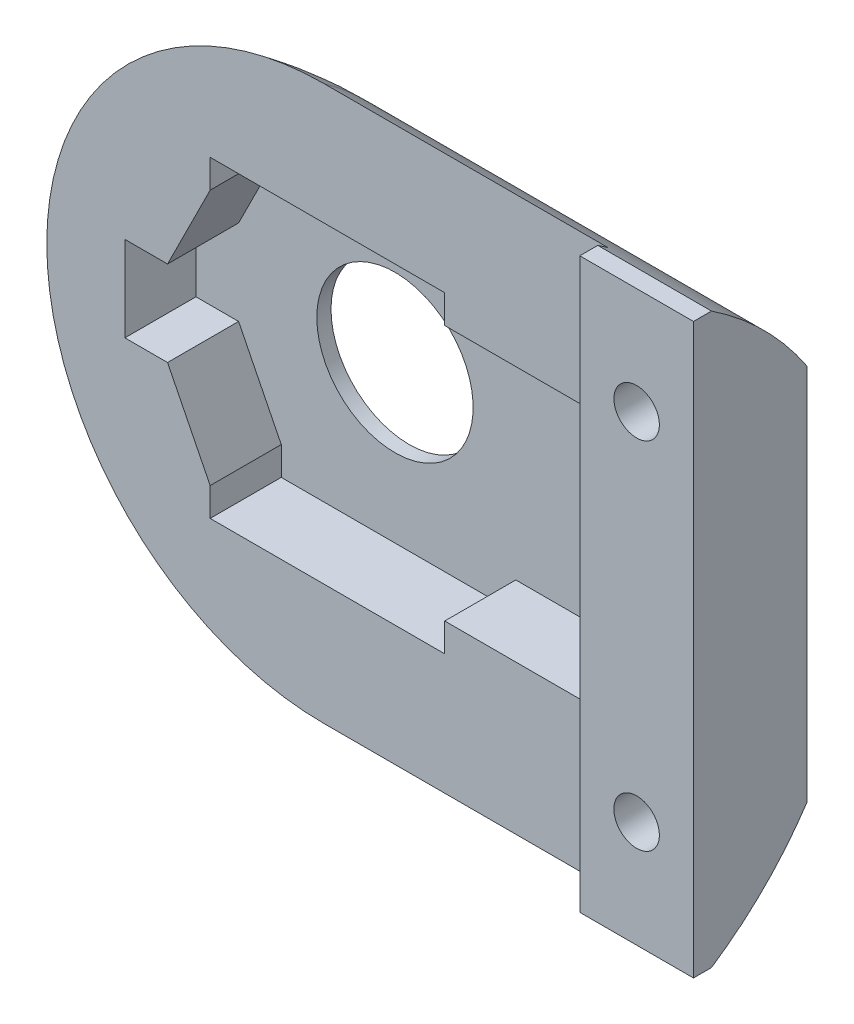
from build123d import *

# Parameters (mm, degrees)
SKETCH1_R           = 10
BOSS_EXTRUDE1_DEPTH = 4
BODY_START          = 5
SKETCH2_R           = 10
BODY_HOLE_DEPTH     = 2
SKETCH5_R           = 0.8
SCREW_HOLES_DEPTH   = 5
SKETCH6_R           = 1.25
SCREW_HEADS_DEPTH   = 2
POT_START           = 0.5
POT_INSERT_DEPTH    = 2.5
SKETCH4_R           = 2.75
POT_HOLE_DEPTH      = 5
CUT_REVOLVE6_ANGLE  = 180
CUT_EXTRUDE1_DEPTH  = 14.999999999


with BuildPart() as part:
    # Sketch1 → Boss-Extrude1 (new body)
    with BuildSketch(Plane.XY):
        Circle(SKETCH1_R)
        with BuildLine():
            Line((13.999999999, 10), (-1e-09, 10))
            ThreePointArc((-1e-09, 10), (7.071067811, 7.071067812), (9.999999999, 0))
            ThreePointArc((9.999999999, 0), (7.071067811, -7.071067812), (-1e-09, -10))
            Line((-1e-09, -10), (13.999999999, -10))
            Line((13.999999999, -10), (13.999999999, 10))
        make_face()
    extrude(amount=BOSS_EXTRUDE1_DEPTH)

    # Sketch2 → Body Hole (cut)
    with BuildSketch(Plane.XY.offset(BODY_START)):
        Circle(SKETCH2_R)
        with BuildLine():
            Line((9.999999999, 10), (-1e-09, 10))
            ThreePointArc((-1e-09, 10), (7.071067811, 7.071067812), (9.999999999, 0))
            Line((9.999999999, 0), (9.999999999, 10))
        make_face()
        with BuildLine():
            Line((9.999999999, -10), (9.999999999, 0))
            ThreePointArc((9.999999999, 0), (7.071067811, -7.071067812), (-1e-09, -10))
            Line((-1e-09, -10), (9.999999999, -10))
        make_face()
    extrude(amount=-BODY_HOLE_DEPTH, mode=Mode.SUBTRACT)

    # Sketch5 → Screw Holes (cut, through all)
    with BuildSketch(Plane.XY):
        with Locations((11.999999999, 6.25)):
            Circle(SKETCH5_R)
        with Locations((11.999999999, -6.25)):
            Circle(SKETCH5_R)
    extrude(amount=SCREW_HOLES_DEPTH, mode=Mode.SUBTRACT)

    # Sketch6 → Screw Heads (cut)
    with BuildSketch(Plane.XY):
        with Locations((11.999999999, -6.25)):
            Circle(SKETCH6_R)
    extrude(amount=SCREW_HEADS_DEPTH, mode=Mode.SUBTRACT)

    # Sketch3 → Pot Insert (cut)
    with BuildSketch(Plane(origin=(28.28760271, 0, 0), x_dir=(1, 0, 0), z_dir=(0, 0, 1)).offset(POT_START)):
        Polygon((-35.287602709, 0), (-35.287602709, -1.5), (-33.787602709, -1.5), (-32.287602709, -4.5), (-32.287602709, -5.5), (-28.287602709, -5.5), (-24.037602709, -5.5), (-24.037602709, -4.5), (-18.787602709, -4.5), (-18.787602709, 0), (-18.787602709, 4.5), (-24.037602709, 4.5), (-24.037602709, 5.5), (-28.287602709, 5.5), (-32.287602709, 5.5), (-32.287602709, 4.5), (-33.787602709, 1.5), (-35.287602709, 1.5), align=None)
    extrude(amount=POT_INSERT_DEPTH, mode=Mode.SUBTRACT)

    # Sketch4 → Pot Hole (cut, through all)
    with BuildSketch(Plane.XY):
        Circle(SKETCH4_R)
    extrude(amount=POT_HOLE_DEPTH, mode=Mode.SUBTRACT)

    # Sketch11 → Cut-Revolve6 (revolve, cut)
    with BuildSketch(Plane(origin=(0, 0, 0), x_dir=(0, 0, -1), z_dir=(1, 0, 0))):
        with BuildLine():
            Line((1.680646386, 2.75), (2, 2.75))
            Line((2, 2.75), (2, 12))
            Line((2, 12), (-10, 12))
            ThreePointArc((-10, 12), (-2.550167787, 9.407443861), (1.680646386, 2.75))
        make_face()
    revolve(axis=Axis((0, 0, 0), (0, 0, 1)), revolution_arc=CUT_REVOLVE6_ANGLE, mode=Mode.SUBTRACT)

    # Sketch13 → Cut-Extrude1 (cut, through all)
    with BuildSketch(Plane(origin=(0, 0, 0), x_dir=(0, 0, -1), z_dir=(1, 0, 0))):
        with BuildLine():
            Line((2, 12), (-10, 12))
            ThreePointArc((-10, 12), (-1.514718626, 8.485281374), (2, 0))
            Line((2, 0), (2, 12))
        make_face()
        with BuildLine():
            Line((2, 0), (2, -12))
            Line((2, -12), (-10, -12))
            ThreePointArc((-10, -12), (-1.514718626, -8.485281374), (2, 0))
        make_face()
    extrude(amount=CUT_EXTRUDE1_DEPTH, mode=Mode.SUBTRACT)


solid = part.part
